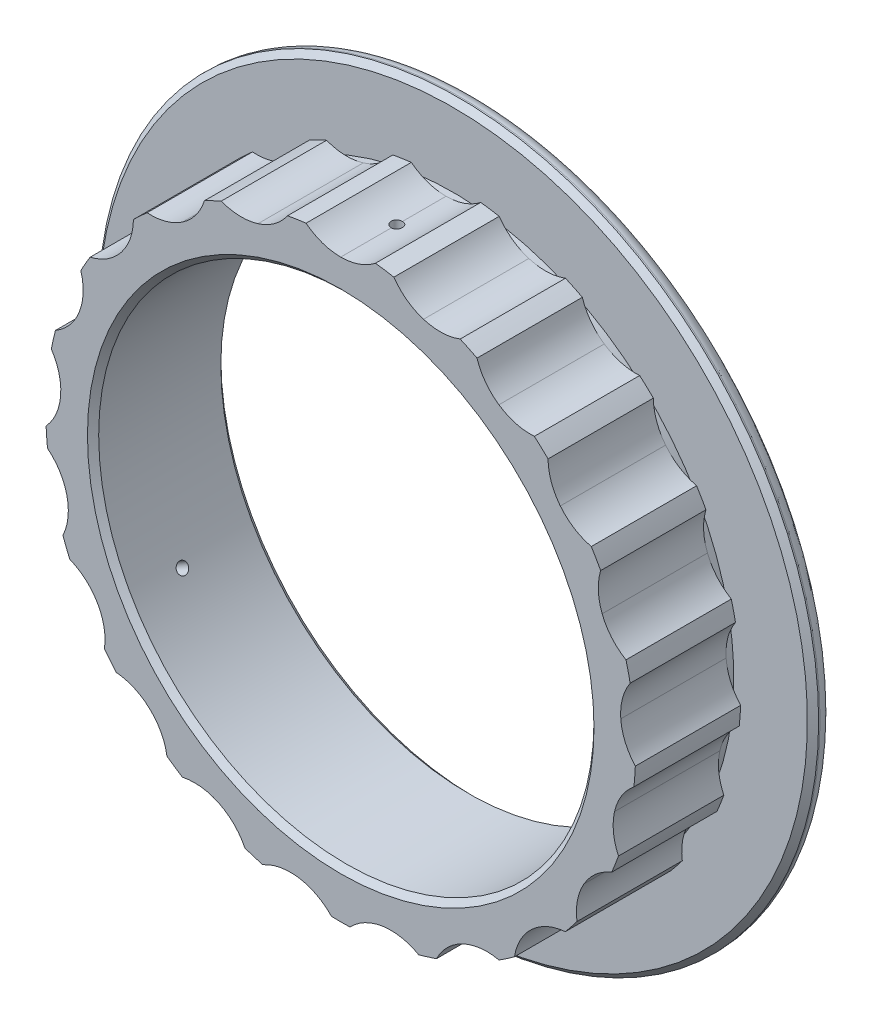
from build123d import *

# Parameters (mm, degrees)
SKETCH2_R               = 63.5
SKETCH2_R_2             = 56
EXTRUDE1_DEPTH          = 12.7
EXTRUDE2_START          = -11.1125
EXTRUDE2_DEPTH          = 23.8125
CIRPATTERN1_COUNT       = 21
SKETCH4_R               = 81.4
SKETCH4_R_2             = 56
EXTRUDE3_DEPTH          = 4.7625
CHAMFER1_SIZE           = 1.27
FILLET2_R               = 3.175
CHAMFER2_SIZE           = 1.27
CUT_EXTRUDE1_REACH      = 177.252
CUT_EXTRUDE1_END_RADIUS = 56
SKETCH5_R               = 1.27
CIRPATTERN2_COUNT       = 3


with BuildPart() as part:
    # Sketch2 → Extrude1 (new, symmetric)
    with BuildSketch(Plane.XY):
        with Locations((0, -72.814769422)):
            Circle(SKETCH2_R)
        with Locations((0, -72.814769422)):
            Circle(SKETCH2_R_2, mode=Mode.SUBTRACT)
    extrude(amount=EXTRUDE1_DEPTH, both=True)

    # Sketch3 → Extrude2 (add)
    with BuildSketch(Plane.XY.offset(EXTRUDE2_START)):
        with BuildLine():
            ThreePointArc((-18.716625, -12.135794904), (-14.956634661, -10.246475439), (-12.020388016, -7.232257295))
            ThreePointArc((-12.020388016, -7.232257295), (-9.937214592, -6.884447178), (-7.844070361, -6.602790255))
            ThreePointArc((-7.844070361, -6.602790255), (-4.149827431, -8.617641257), (0, -9.314769422))
            ThreePointArc((0, -9.314769422), (-9.464013897, -10.023986333), (-18.716625, -12.135794904))
        make_face()
    extrude2 = extrude(amount=EXTRUDE2_DEPTH)

    # CirPattern1: Extrude2 ×21 about axis
    cirpattern1_axis = Axis((0, -72.814769422, 0), (0, 0, 1))
    for i in range(1, CIRPATTERN1_COUNT):
        add(extrude2.rotate(cirpattern1_axis, i * 360 / CIRPATTERN1_COUNT))

    # Sketch4 → Extrude3 (add)
    with BuildSketch(Plane(origin=(0, 0, -12.7), x_dir=(-1, 0, 0), z_dir=(0, 0, -1))):
        with Locations(Location((0, -72.814769422, 0), (0, 0, 180))):
            Circle(SKETCH4_R)
        with Locations((0, -72.814769422)):
            Circle(SKETCH4_R_2, mode=Mode.SUBTRACT)
    extrude(amount=EXTRUDE3_DEPTH)

    # Chamfer1
    chamfer1_edges = [part.edges().sort_by_distance(p)[0] for p in [
        (56, -72.814769422, -17.4625),
        (-56, -72.814769422, 12.7),
    ]]
    chamfer(chamfer1_edges, length=CHAMFER1_SIZE)

    # Fillet2
    fillet2_edges = [part.edges().sort_by_distance(p)[0] for p in [
        (-81.4, -72.814769422, -17.4625),
    ]]
    fillet(fillet2_edges, radius=FILLET2_R)

    # Chamfer2
    chamfer2_edges = [part.edges().sort_by_distance(p)[0] for p in [
        (-81.4, -72.814769422, -12.7),
    ]]
    chamfer(chamfer2_edges, length=CHAMFER2_SIZE)

    # Cut-Extrude1: up to this cylinder (the profile starts outside it)
    cut_extrude1_end = Plane(origin=(0, -72.814769422, 0), z_dir=(0, 0, -1)) * Cylinder(CUT_EXTRUDE1_END_RADIUS, 467.504, mode=Mode.PRIVATE)
    # Sketch5 → Cut-Extrude1 (cut, up to the surface)
    with BuildSketch(Plane(origin=(0, 0, 0), x_dir=(1, 0, 0), z_dir=(0, 1, 0)), mode=Mode.PRIVATE) as cut_extrude1_sk1:
        with Locations(Location((0, 0, 0), (0, 0, 270))):
            Circle(SKETCH5_R)
    cut_extrude1_tool1 = extrude(cut_extrude1_sk1.sketch, amount=-CUT_EXTRUDE1_REACH, mode=Mode.PRIVATE) - cut_extrude1_end
    cut_extrude1 = cut_extrude1_tool1.solids().sort_by_distance((0, 0, 0))[0]
    add(cut_extrude1, mode=Mode.SUBTRACT)

    # CirPattern2: Cut-Extrude1 ×3 about axis
    cirpattern2_axis = Axis((0, -72.814769422, 12.7), (0, 0, -1))
    for i in range(1, CIRPATTERN2_COUNT):
        add(cut_extrude1.rotate(cirpattern2_axis, i * 360 / CIRPATTERN2_COUNT), mode=Mode.SUBTRACT)


solid = part.part
